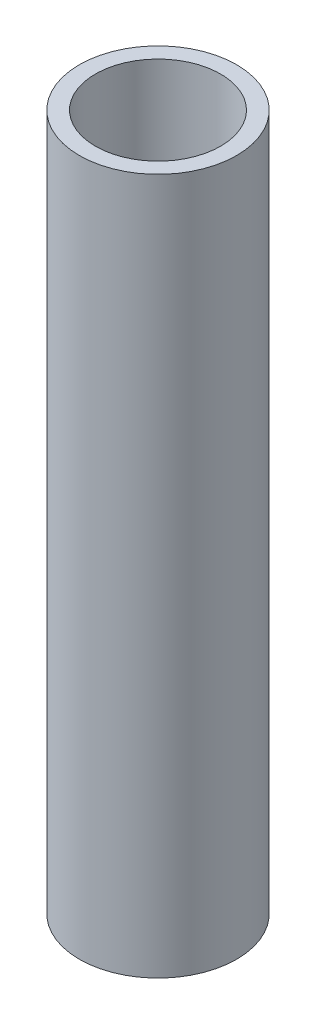
from build123d import *

# Parameters (mm, degrees)
SKETCH1_R           = 11.811
BOSS_EXTRUDE1_DEPTH = 104.521
SKETCH2_R           = 9.398
CUT_EXTRUDE1_DEPTH  = 99.441
SKETCH3_R           = 6.096
CUT_EXTRUDE2_DEPTH  = 105.521


with BuildPart() as part:
    # Sketch1 → Boss-Extrude1 (new body)
    with BuildSketch(Plane(origin=(0, 0, 0), x_dir=(1, 0, 0), z_dir=(0, 1, 0))):
        Circle(SKETCH1_R)
    extrude(amount=-BOSS_EXTRUDE1_DEPTH)

    # Sketch2 → Cut-Extrude1 (cut)
    with BuildSketch(Plane(origin=(0, 0, 0), x_dir=(1, 0, 0), z_dir=(0, 1, 0))):
        Circle(SKETCH2_R)
    extrude(amount=-CUT_EXTRUDE1_DEPTH, mode=Mode.SUBTRACT)

    # Sketch3 → Cut-Extrude2 (cut, through all)
    with BuildSketch(Plane(origin=(0, 0, 0), x_dir=(1, 0, 0), z_dir=(0, 1, 0))):
        Circle(SKETCH3_R)
    extrude(amount=-CUT_EXTRUDE2_DEPTH, mode=Mode.SUBTRACT)


solid = part.part
